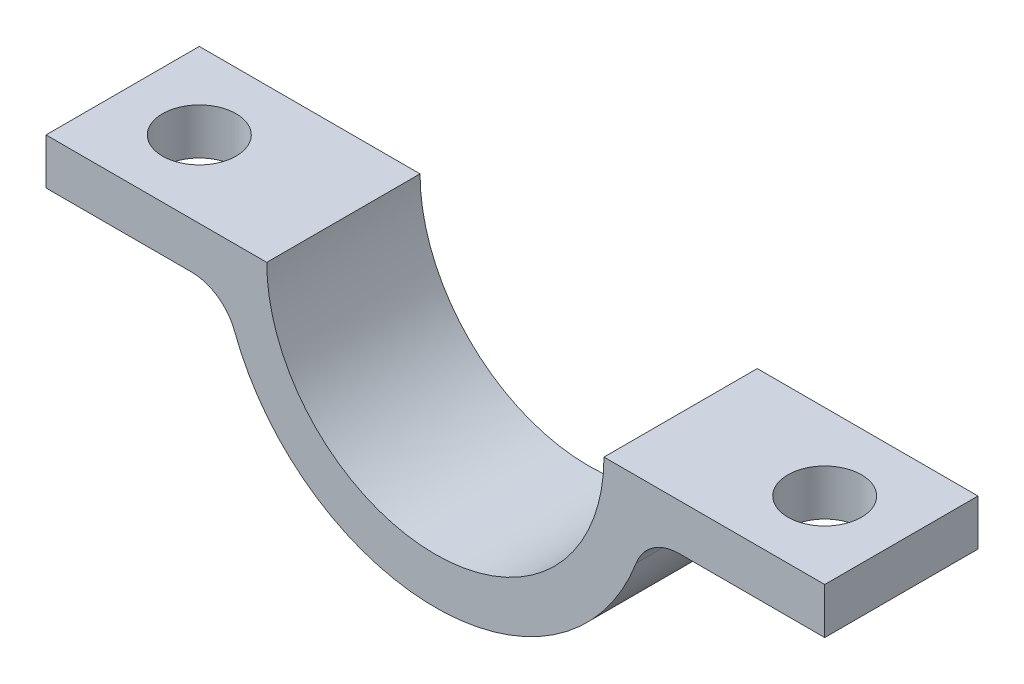
from build123d import *

# Parameters (mm, degrees)
BOSS_EXTRUDE1_DEPTH = 2.5
SKETCH2_R           = 1.2
CUT_EXTRUDE1_DEPTH  = 8
FILLET1_R           = 1.5


with BuildPart() as part:
    # Sketch1 → Boss-Extrude1 (new body, symmetric)
    with BuildSketch(Plane.XY):
        with BuildLine():
            Line((5.5, 0), (12.7, 0))
            Line((12.7, 0), (12.7, -1.5))
            Line((12.7, -1.5), (6.837397166, -1.5))
            ThreePointArc((6.837397166, -1.5), (0, -7), (-6.837397166, -1.5))
            Line((-6.837397166, -1.5), (-12.7, -1.5))
            Line((-12.7, -1.5), (-12.7, 0))
            Line((-12.7, 0), (-5.5, 0))
            ThreePointArc((-5.5, 0), (0, -5.5), (5.5, 0))
        make_face()
    extrude(amount=BOSS_EXTRUDE1_DEPTH, both=True)

    # Sketch2 → Cut-Extrude1 (cut, through all)
    with BuildSketch(Plane(origin=(0, 0, 0), x_dir=(1, 0, 0), z_dir=(0, 1, 0))):
        with Locations((-10.2, 0)):
            Circle(SKETCH2_R)
        with Locations((10.2, 0)):
            Circle(SKETCH2_R)
    extrude(amount=-CUT_EXTRUDE1_DEPTH, mode=Mode.SUBTRACT)

    # Fillet1
    fillet1_edges = [part.edges().sort_by_distance(p)[0] for p in [
        (6.837397166, -1.5, 0),
        (-6.837397166, -1.5, 0),
    ]]
    fillet(fillet1_edges, radius=FILLET1_R)


solid = part.part
